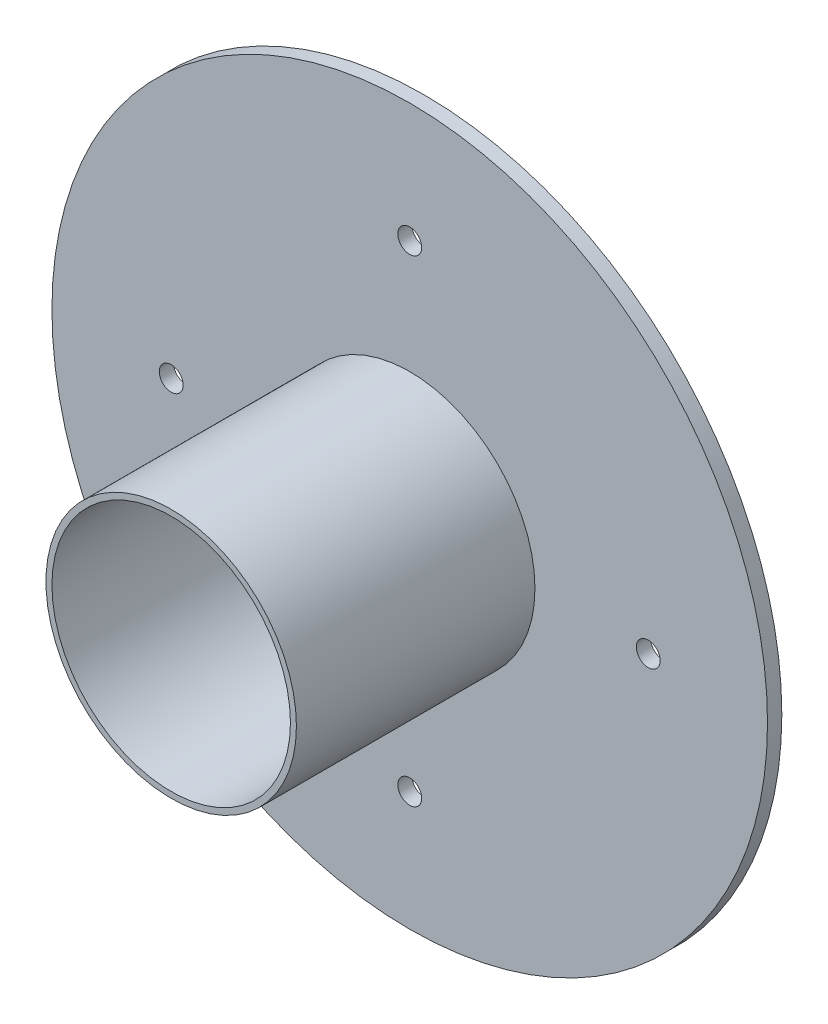
from build123d import *

# Parameters (mm, degrees)
SKETCH2_R           = 150
BOSS_EXTRUDE1_DEPTH = 6
SKETCH3_R           = 52.5
SKETCH3_R_2         = 50
BOSS_EXTRUDE2_DEPTH = 100
SKETCH4_R           = 5
CUT_EXTRUDE1_DEPTH  = 100


with BuildPart() as part:
    # Sketch2 → Boss-Extrude1 (new body)
    with BuildSketch(Plane.XY):
        Circle(SKETCH2_R)
    extrude(amount=BOSS_EXTRUDE1_DEPTH)

    # Sketch3 → Boss-Extrude2 (add)
    with BuildSketch(Plane.XY.offset(6)):
        Circle(SKETCH3_R)
        Circle(SKETCH3_R_2, mode=Mode.SUBTRACT)
    extrude(amount=BOSS_EXTRUDE2_DEPTH)

    # Sketch4 → Cut-Extrude1 (cut)
    with BuildSketch(Plane.XY.offset(6)):
        with Locations((100, 0)):
            Circle(SKETCH4_R)
        with Locations((0, -100)):
            Circle(SKETCH4_R)
        with Locations((-100, 0)):
            Circle(SKETCH4_R)
        with Locations((0, 100)):
            Circle(SKETCH4_R)
    extrude(amount=-CUT_EXTRUDE1_DEPTH, mode=Mode.SUBTRACT)


solid = part.part
